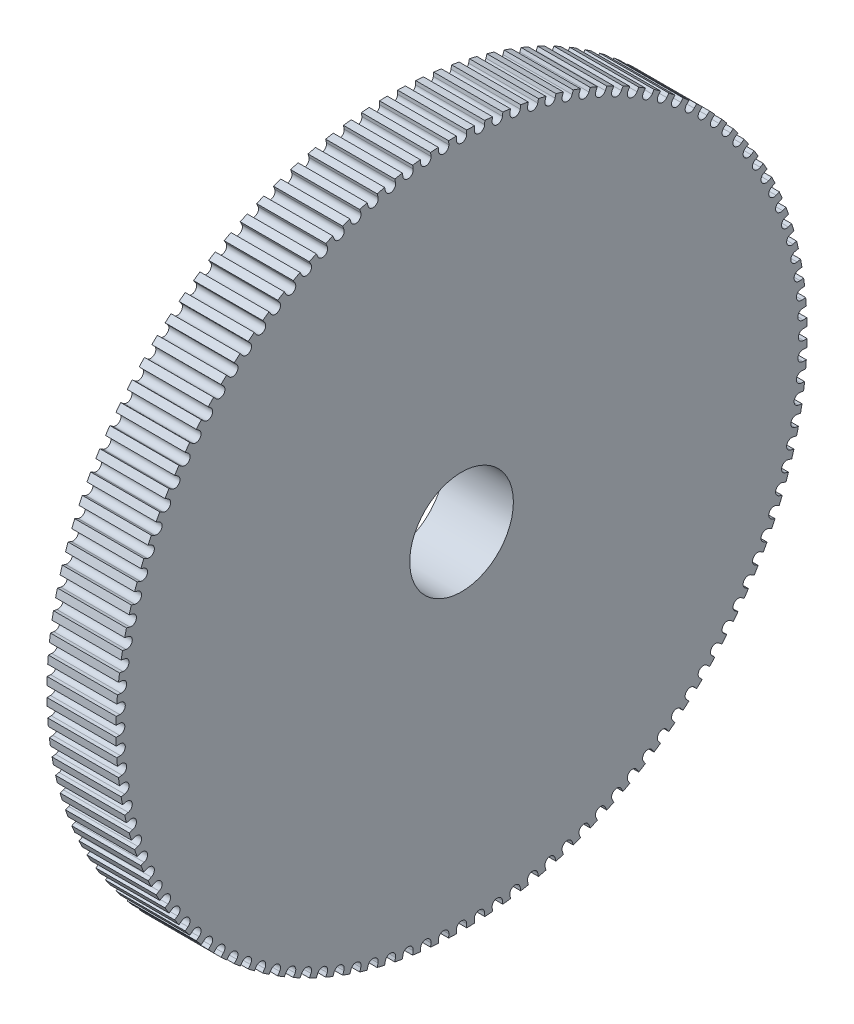
from build123d import *

# Parameters (mm, degrees)
SKETCH1_R           = 40
SKETCH1_R_2         = 6
BOSS_EXTRUDE1_DEPTH = 8
CUT_EXTRUDE1_DEPTH  = 10
CIRPATTERN1_COUNT   = 120


with BuildPart() as part:
    # Sketch1 → Boss-Extrude1 (new body)
    with BuildSketch(Plane(origin=(0, 0, 0), x_dir=(0, 0, -1), z_dir=(1, 0, 0))):
        Circle(SKETCH1_R)
        Circle(SKETCH1_R_2, mode=Mode.SUBTRACT)
    extrude(amount=BOSS_EXTRUDE1_DEPTH)

    # Sketch2 → Cut-Extrude1 (cut)
    with BuildSketch(Plane(origin=(8, 0, 0), x_dir=(0, 0, -1), z_dir=(1, 0, 0))):
        with BuildLine():
            Line((0.6, 47.353467179), (0.6, 39.583662298))
            ThreePointArc((0.6, 39.583662298), (0, 38.983662298), (-0.6, 39.583662298))
            Line((-0.6, 39.583662298), (-0.6, 47.353467179))
            ThreePointArc((-0.6, 47.353467179), (0, 47.953467179), (0.6, 47.353467179))
        make_face()
    cut_extrude1 = extrude(amount=-CUT_EXTRUDE1_DEPTH, mode=Mode.SUBTRACT)

    # CirPattern1: Cut-Extrude1 ×120 about axis
    cirpattern1_axis = Axis((0, 0, 0), (1, 0, 0))
    for i in range(1, CIRPATTERN1_COUNT):
        add(cut_extrude1.rotate(cirpattern1_axis, i * 360 / CIRPATTERN1_COUNT), mode=Mode.SUBTRACT)


solid = part.part
